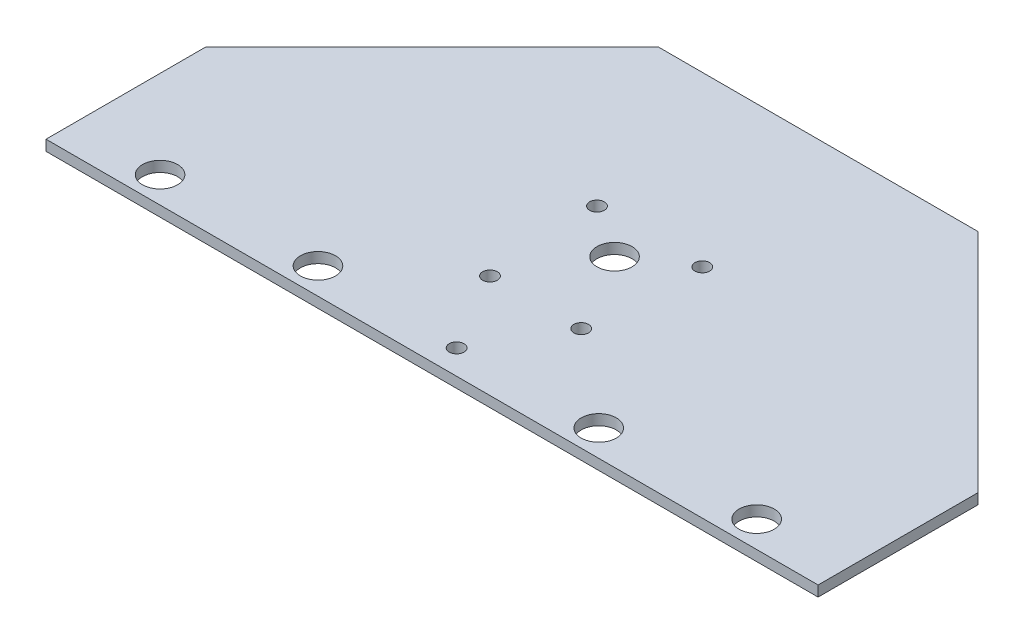
from build123d import *

# Parameters (mm, degrees)
EXTRUDE1_DEPTH     = 3
SKETCH2_R          = 5
CUT_EXTRUDE1_DEPTH = 147.065416139
SKETCH7_R          = 5
CUT_EXTRUDE6_DEPTH = 147.065416139
SKETCH8_R          = 2.1
CUT_EXTRUDE7_DEPTH = 188.407399972


with BuildPart() as part:
    # Sketch1 → Extrude1 (new body)
    with BuildSketch(Plane(origin=(0, 0, 0), x_dir=(1, 0, 0), z_dir=(0, 1, 0))):
        Polygon((-110, -13.947380088), (-110, 31.616111773), (-45.563491861, 96.052619912), (0, 96.052619912), (45.563491861, 96.052619912), (110, 31.616111773), (110, -13.947380088), align=None)
    extrude(amount=EXTRUDE1_DEPTH)

    # Sketch2 → Cut-Extrude1 (cut, through all)
    with BuildSketch(Plane(origin=(0, 3, 0), x_dir=(-1, 0, 0), z_dir=(0, 1, 0))):
        with Locations((85, 6.447380088)):
            Circle(SKETCH2_R)
        with Locations((40, 6.447380088)):
            Circle(SKETCH2_R)
        with Locations((-40, 6.447380088)):
            Circle(SKETCH2_R)
        with Locations((-85, 6.447380088)):
            Circle(SKETCH2_R)
    extrude(amount=-CUT_EXTRUDE1_DEPTH, mode=Mode.SUBTRACT)

    # Sketch7 → Cut-Extrude6 (cut, through all)
    with BuildSketch(Plane(origin=(0, 3, 0), x_dir=(-1, 0, 0), z_dir=(0, 1, 0))):
        with Locations((0, -38.052619912)):
            Circle(SKETCH7_R)
    extrude(amount=-CUT_EXTRUDE6_DEPTH, mode=Mode.SUBTRACT)

    # Sketch8 → Cut-Extrude7 (cut, through all)
    with BuildSketch(Plane(origin=(49.267366711, 3, 2.671437264), x_dir=(-1, 0, 0), z_dir=(0, 1, 0))):
        with Locations((64.267366711, -50.724057176)):
            Circle(SKETCH8_R)
        with Locations((34.267366711, -50.724057176)):
            Circle(SKETCH8_R)
        with Locations((36.277366711, -18.224057176)):
            Circle(SKETCH8_R)
        with Locations((62.257366711, -18.224057176)):
            Circle(SKETCH8_R)
        with Locations((49.267366711, 4.275942824)):
            Circle(SKETCH8_R)
    extrude(amount=-CUT_EXTRUDE7_DEPTH, mode=Mode.SUBTRACT)


solid = part.part
